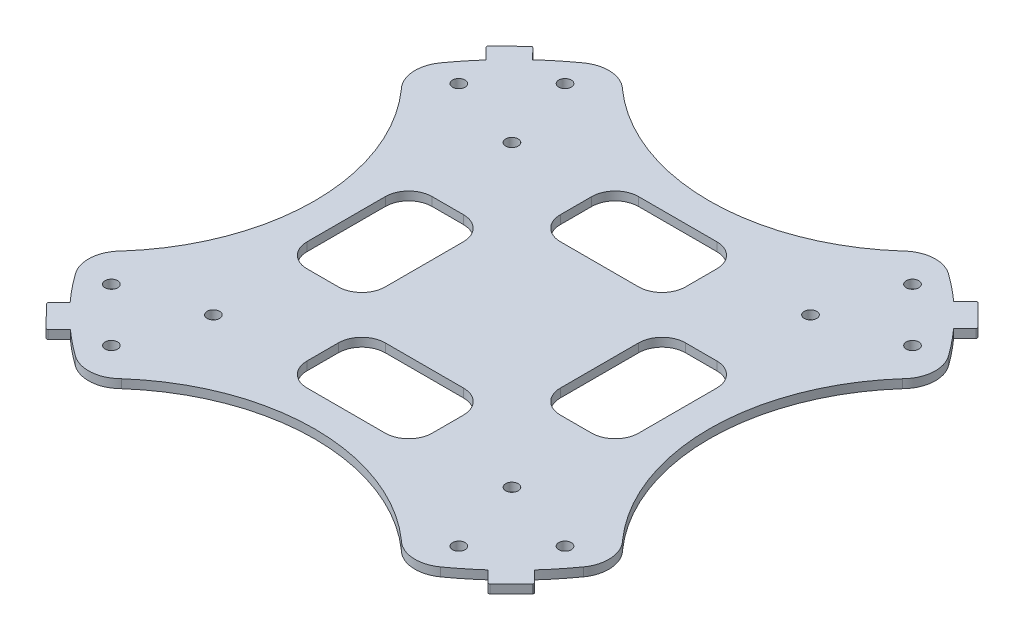
from build123d import *

# Parameters (mm, degrees)
SKETCH1_R           = 1.015999997
SKETCH1_R_2         = 1.015999998
BOSS_EXTRUDE1_DEPTH = 1.397
CUT_EXTRUDE1_DEPTH  = 1.397
BOSS_EXTRUDE2_DEPTH = 0.01


with BuildPart() as part:
    # Sketch1 → Boss-Extrude1 (new body)
    with BuildSketch(Plane(origin=(0, 0, 0), x_dir=(1, 0, 0), z_dir=(0, 1, 0))):
        with BuildLine():
            Line((39.582900137, 36.114993353), (36.135807663, 39.558338119))
            ThreePointArc((36.135807663, 39.558338119), (35.957741585, 39.627761729), (35.781684056, 39.553391627))
            Line((35.781684056, 39.553391627), (33.985632879, 37.75734045))
            ThreePointArc((33.985632879, 37.75734045), (31.864995739, 39.563392759), (29.648553616, 41.25049416))
            ThreePointArc((29.648553616, 41.25049416), (26.08463695, 42.240855836), (22.7274362, 40.687948442))
            ThreePointArc((22.7274362, 40.687948442), (0, 32.054645119), (-22.7274362, 40.687948442))
            ThreePointArc((-22.7274362, 40.687948442), (-26.08463695, 42.240855836), (-29.648553616, 41.25049416))
            ThreePointArc((-29.648553616, 41.25049416), (-31.979190339, 39.471146237), (-34.203281642, 37.560291864))
            Line((-34.203281642, 37.560291864), (-35.891842785, 39.288069847))
            ThreePointArc((-35.891842785, 39.288069847), (-36.070582137, 39.364521411), (-36.251029365, 39.292193022))
            Line((-36.251029365, 39.292193022), (-39.722106603, 35.899901777))
            ThreePointArc((-39.722106603, 35.899901777), (-39.798570717, 35.719704686), (-39.724180022, 35.538641777))
            Line((-39.724180022, 35.538641777), (-37.952779126, 33.76724088))
            ThreePointArc((-37.952779126, 33.76724088), (-39.65514495, 31.750739818), (-41.25049416, 29.648553616))
            ThreePointArc((-41.25049416, 29.648553616), (-42.240855836, 26.08463695), (-40.687948442, 22.7274362))
            ThreePointArc((-40.687948442, 22.7274362), (-32.054645119, 0), (-40.687948442, -22.7274362))
            ThreePointArc((-40.687948442, -22.7274362), (-42.240855836, -26.08463695), (-41.25049416, -29.648553616))
            ThreePointArc((-41.25049416, -29.648553616), (-39.491481287, -31.954074947), (-37.603777167, -34.155467245))
            Line((-37.603777167, -34.155467245), (-39.342333505, -35.894023583))
            ThreePointArc((-39.342333505, -35.894023583), (-39.416724199, -36.072170919), (-39.34438326, -36.251160408))
            Line((-39.34438326, -36.251160408), (-35.996846779, -39.67644344))
            ThreePointArc((-35.996846779, -39.67644344), (-35.8116648, -39.777312417), (-35.614113895, -39.703552292))
            Line((-35.614113895, -39.703552292), (-33.818062671, -37.907501068))
            ThreePointArc((-33.818062671, -37.907501068), (-31.777299231, -39.633864984), (-29.648553616, -41.25049416))
            ThreePointArc((-29.648553616, -41.25049416), (-26.08463695, -42.240855836), (-22.7274362, -40.687948442))
            ThreePointArc((-22.7274362, -40.687948442), (0, -32.054645119), (22.7274362, -40.687948442))
            ThreePointArc((22.7274362, -40.687948442), (26.08463695, -42.240855836), (29.648553616, -41.25049416))
            ThreePointArc((29.648553616, -41.25049416), (31.839816037, -39.583659694), (33.937557164, -37.800558378))
            Line((33.937557164, -37.800558378), (35.712874192, -39.617107153))
            ThreePointArc((35.712874192, -39.617107153), (35.89865706, -39.693541904), (36.081857691, -39.611109667))
            Line((36.081857691, -39.611109667), (39.53818925, -36.154778109))
            ThreePointArc((39.53818925, -36.154778109), (39.581113192, -35.9880354), (39.507835585, -35.832227866))
            Line((39.507835585, -35.832227866), (37.71178436, -34.036176641))
            ThreePointArc((37.71178436, -34.036176641), (39.542043021, -31.891485286), (41.25049416, -29.648553616))
            ThreePointArc((41.25049416, -29.648553616), (42.240855836, -26.08463695), (40.687948442, -22.7274362))
            ThreePointArc((40.687948442, -22.7274362), (32.054645119, 0), (40.687948442, 22.7274362))
            ThreePointArc((40.687948442, 22.7274362), (42.240855836, 26.08463695), (41.25049416, 29.648553616))
            ThreePointArc((41.25049416, 29.648553616), (39.563392759, 31.864995739), (37.75734045, 33.985632879))
            Line((37.75734045, 33.985632879), (39.573889176, 35.76094986))
            ThreePointArc((39.573889176, 35.76094986), (39.650275245, 35.936142133), (39.582900137, 36.114993353))
        make_face()
        with Locations((-28.220170249, 36.841216125)):
            Circle(SKETCH1_R, mode=Mode.SUBTRACT)
        with Locations((-36.841216125, 28.220170249)):
            Circle(SKETCH1_R, mode=Mode.SUBTRACT)
        with Locations((-24.24546392, 24.24546392)):
            Circle(SKETCH1_R_2, mode=Mode.SUBTRACT)
        with Locations((28.220170249, 36.841216125)):
            Circle(SKETCH1_R, mode=Mode.SUBTRACT)
        with Locations((36.841216125, 28.220170249)):
            Circle(SKETCH1_R, mode=Mode.SUBTRACT)
        with Locations((24.24546392, 24.24546392)):
            Circle(SKETCH1_R_2, mode=Mode.SUBTRACT)
        with Locations((36.841216125, -28.220170249)):
            Circle(SKETCH1_R, mode=Mode.SUBTRACT)
        with Locations((28.220170249, -36.841216125)):
            Circle(SKETCH1_R, mode=Mode.SUBTRACT)
        with Locations((24.24546392, -24.24546392)):
            Circle(SKETCH1_R_2, mode=Mode.SUBTRACT)
        with Locations((-28.220170249, -36.841216125)):
            Circle(SKETCH1_R, mode=Mode.SUBTRACT)
        with Locations((-36.841216125, -28.220170249)):
            Circle(SKETCH1_R, mode=Mode.SUBTRACT)
        with Locations((-24.24546392, -24.24546392)):
            Circle(SKETCH1_R_2, mode=Mode.SUBTRACT)
    extrude(amount=BOSS_EXTRUDE1_DEPTH)

    # Sketch3 → Cut-Extrude1 (cut)
    with BuildSketch(Plane(origin=(0, 1.397, 0), x_dir=(1, 0, 0), z_dir=(0, 1, 0))):
        with BuildLine():
            Line((26.924, 6.35), (26.924, -6.35))
            ThreePointArc((26.924, -6.35), (25.808076836, -9.044076836), (23.114, -10.16))
            Line((23.114, -10.16), (18.034, -10.16))
            ThreePointArc((18.034, -10.16), (15.339923164, -9.044076836), (14.224, -6.35))
            Line((14.224, -6.35), (14.224, 6.35))
            ThreePointArc((14.224, 6.35), (15.339923164, 9.044076836), (18.034, 10.16))
            Line((18.034, 10.16), (23.114, 10.16))
            ThreePointArc((23.114, 10.16), (25.808076836, 9.044076836), (26.924, 6.35))
        make_face()
        with BuildLine():
            Line((-6.35, 26.924), (6.35, 26.924))
            ThreePointArc((6.35, 26.924), (9.044076836, 25.808076836), (10.16, 23.114))
            Line((10.16, 23.114), (10.16, 18.034))
            ThreePointArc((10.16, 18.034), (9.044076836, 15.339923164), (6.35, 14.224))
            Line((6.35, 14.224), (-6.35, 14.224))
            ThreePointArc((-6.35, 14.224), (-9.044076836, 15.339923164), (-10.16, 18.034))
            Line((-10.16, 18.034), (-10.16, 23.114))
            ThreePointArc((-10.16, 23.114), (-9.044076836, 25.808076836), (-6.35, 26.924))
        make_face()
        with BuildLine():
            Line((6.35, -26.924), (-6.35, -26.924))
            ThreePointArc((-6.35, -26.924), (-9.044076836, -25.808076836), (-10.16, -23.114))
            Line((-10.16, -23.114), (-10.16, -18.034))
            ThreePointArc((-10.16, -18.034), (-9.044076836, -15.339923164), (-6.35, -14.224))
            Line((-6.35, -14.224), (6.35, -14.224))
            ThreePointArc((6.35, -14.224), (9.044076836, -15.339923164), (10.16, -18.034))
            Line((10.16, -18.034), (10.16, -23.114))
            ThreePointArc((10.16, -23.114), (9.044076836, -25.808076836), (6.35, -26.924))
        make_face()
        with BuildLine():
            Line((-26.924, -6.35), (-26.924, 6.35))
            ThreePointArc((-26.924, 6.35), (-25.808076836, 9.044076836), (-23.114, 10.16))
            Line((-23.114, 10.16), (-18.034, 10.16))
            ThreePointArc((-18.034, 10.16), (-15.339923164, 9.044076836), (-14.224, 6.35))
            Line((-14.224, 6.35), (-14.224, -6.35))
            ThreePointArc((-14.224, -6.35), (-15.339923164, -9.044076836), (-18.034, -10.16))
            Line((-18.034, -10.16), (-23.114, -10.16))
            ThreePointArc((-23.114, -10.16), (-25.808076836, -9.044076836), (-26.924, -6.35))
        make_face()
    extrude(amount=-CUT_EXTRUDE1_DEPTH, mode=Mode.SUBTRACT)

    # Sketch4 → Boss-Extrude2 (add)
    with BuildSketch(Plane.XZ):
        with BuildLine():
            Line((33.985632879, -37.75734045), (35.781684056, -39.553391627))
            ThreePointArc((35.781684056, -39.553391627), (35.957741585, -39.627761729), (36.135807663, -39.558338119))
            Line((36.135807663, -39.558338119), (39.582900137, -36.114993353))
            ThreePointArc((39.582900137, -36.114993353), (39.650275245, -35.936142133), (39.573889176, -35.76094986))
            Line((39.573889176, -35.76094986), (37.75734045, -33.985632879))
            ThreePointArc((37.75734045, -33.985632879), (39.563392759, -31.864995739), (41.25049416, -29.648553616))
            ThreePointArc((41.25049416, -29.648553616), (42.240855836, -26.08463695), (40.687948442, -22.7274362))
            ThreePointArc((40.687948442, -22.7274362), (32.054645119, 0), (40.687948442, 22.7274362))
            ThreePointArc((40.687948442, 22.7274362), (42.240855836, 26.08463695), (41.25049416, 29.648553616))
            ThreePointArc((41.25049416, 29.648553616), (39.542043021, 31.891485286), (37.71178436, 34.036176641))
            Line((37.71178436, 34.036176641), (39.507835585, 35.832227866))
            ThreePointArc((39.507835585, 35.832227866), (39.581113192, 35.9880354), (39.53818925, 36.154778109))
            Line((39.53818925, 36.154778109), (36.081857691, 39.611109667))
            ThreePointArc((36.081857691, 39.611109667), (35.89865706, 39.693541904), (35.712874192, 39.617107153))
            Line((35.712874192, 39.617107153), (33.937557164, 37.800558378))
            ThreePointArc((33.937557164, 37.800558378), (31.839816037, 39.583659694), (29.648553616, 41.25049416))
            ThreePointArc((29.648553616, 41.25049416), (26.08463695, 42.240855836), (22.7274362, 40.687948442))
            ThreePointArc((22.7274362, 40.687948442), (0, 32.054645119), (-22.7274362, 40.687948442))
            ThreePointArc((-22.7274362, 40.687948442), (-26.08463695, 42.240855836), (-29.648553616, 41.25049416))
            ThreePointArc((-29.648553616, 41.25049416), (-31.777299231, 39.633864984), (-33.818062671, 37.907501068))
            Line((-33.818062671, 37.907501068), (-35.614113895, 39.703552292))
            ThreePointArc((-35.614113895, 39.703552292), (-35.8116648, 39.777312417), (-35.996846779, 39.67644344))
            Line((-35.996846779, 39.67644344), (-39.34438326, 36.251160408))
            ThreePointArc((-39.34438326, 36.251160408), (-39.416724199, 36.072170919), (-39.342333505, 35.894023583))
            Line((-39.342333505, 35.894023583), (-37.603777167, 34.155467245))
            ThreePointArc((-37.603777167, 34.155467245), (-39.491481287, 31.954074947), (-41.25049416, 29.648553616))
            ThreePointArc((-41.25049416, 29.648553616), (-42.240855836, 26.08463695), (-40.687948442, 22.7274362))
            ThreePointArc((-40.687948442, 22.7274362), (-32.054645119, 0), (-40.687948442, -22.7274362))
            ThreePointArc((-40.687948442, -22.7274362), (-42.240855836, -26.08463695), (-41.25049416, -29.648553616))
            ThreePointArc((-41.25049416, -29.648553616), (-39.65514495, -31.750739818), (-37.952779126, -33.76724088))
            Line((-37.952779126, -33.76724088), (-39.724180022, -35.538641777))
            ThreePointArc((-39.724180022, -35.538641777), (-39.798570717, -35.719704686), (-39.722106603, -35.899901777))
            Line((-39.722106603, -35.899901777), (-36.251029365, -39.292193022))
            ThreePointArc((-36.251029365, -39.292193022), (-36.070582137, -39.364521411), (-35.891842785, -39.288069847))
            Line((-35.891842785, -39.288069847), (-34.203281642, -37.560291864))
            ThreePointArc((-34.203281642, -37.560291864), (-31.979190339, -39.471146237), (-29.648553616, -41.25049416))
            ThreePointArc((-29.648553616, -41.25049416), (-26.08463695, -42.240855836), (-22.7274362, -40.687948442))
            ThreePointArc((-22.7274362, -40.687948442), (0, -32.054645119), (22.7274362, -40.687948442))
            ThreePointArc((22.7274362, -40.687948442), (26.08463695, -42.240855836), (29.648553616, -41.25049416))
            ThreePointArc((29.648553616, -41.25049416), (31.864995739, -39.563392759), (33.985632879, -37.75734045))
        make_face()
        with BuildLine():
            Line((34.031947351, -34.975227797), (35.961893128, -36.905173574))
            Line((35.961893128, -36.905173574), (36.912054688, -35.956045038))
            Line((36.912054688, -35.956045038), (34.959646939, -34.047952742))
            ThreePointArc((34.959646939, -34.047952742), (37.396774434, -31.351575111), (39.626458957, -28.481287726))
            ThreePointArc((39.626458957, -28.481287726), (40.245239062, -26.220934367), (39.236939987, -24.105415731))
            ThreePointArc((39.236939987, -24.105415731), (30.054645119, 0), (39.236939987, 24.105415731))
            ThreePointArc((39.236939987, 24.105415731), (40.245239062, 26.220934367), (39.626458957, 28.481287726))
            ThreePointArc((39.626458957, 28.481287726), (37.382115507, 31.369052268), (34.927801218, 34.080620624))
            Line((34.927801218, 34.080620624), (36.855860414, 36.00867982))
            Line((36.855860414, 36.00867982), (35.908611019, 36.955929215))
            Line((35.908611019, 36.955929215), (34.001651749, 35.004680806))
            ThreePointArc((34.001651749, 35.004680806), (31.326819814, 37.417514086), (28.481287726, 39.626458957))
            ThreePointArc((28.481287726, 39.626458957), (26.220934367, 40.245239062), (24.105415731, 39.236939987))
            ThreePointArc((24.105415731, 39.236939987), (0, 30.054645119), (-24.105415731, 39.236939987))
            ThreePointArc((-24.105415731, 39.236939987), (-26.220934367, 40.245239062), (-28.481287726, 39.626458957))
            ThreePointArc((-28.481287726, 39.626458957), (-31.256819816, 37.476008525), (-33.870544531, 35.131555803))
            Line((-33.870544531, 35.131555803), (-35.777951024, 37.038962296))
            Line((-35.777951024, 37.038962296), (-36.707602479, 36.087719682))
            Line((-36.707602479, 36.087719682), (-34.81536034, 34.195477543))
            ThreePointArc((-34.81536034, 34.195477543), (-37.330404584, 31.430572594), (-39.626458957, 28.481287726))
            ThreePointArc((-39.626458957, 28.481287726), (-40.245239062, 26.220934367), (-39.236939987, 24.105415731))
            ThreePointArc((-39.236939987, 24.105415731), (-30.054645119, 0), (-39.236939987, -24.105415731))
            ThreePointArc((-39.236939987, -24.105415731), (-40.245239062, -26.220934367), (-39.626458957, -28.481287726))
            ThreePointArc((-39.626458957, -28.481287726), (-37.497765548, -31.230715312), (-35.178694145, -33.821583024))
            Line((-35.178694145, -33.821583024), (-37.06110436, -35.703993239))
            Line((-37.06110436, -35.703993239), (-36.101840432, -36.641483938))
            Line((-36.101840432, -36.641483938), (-34.257512326, -34.754321303))
            ThreePointArc((-34.257512326, -34.754321303), (-31.463847338, -37.302363339), (-28.481287726, -39.626458957))
            ThreePointArc((-28.481287726, -39.626458957), (-26.220934367, -40.245239062), (-24.105415731, -39.236939987))
            ThreePointArc((-24.105415731, -39.236939987), (0, -30.054645119), (24.105415731, -39.236939987))
            ThreePointArc((24.105415731, -39.236939987), (26.220934367, -40.245239062), (28.481287726, -39.626458957))
            ThreePointArc((28.481287726, -39.626458957), (31.343015614, -37.403948618), (34.031947351, -34.975227797))
        make_face(mode=Mode.SUBTRACT)
    extrude(amount=BOSS_EXTRUDE2_DEPTH)


solid = part.part
